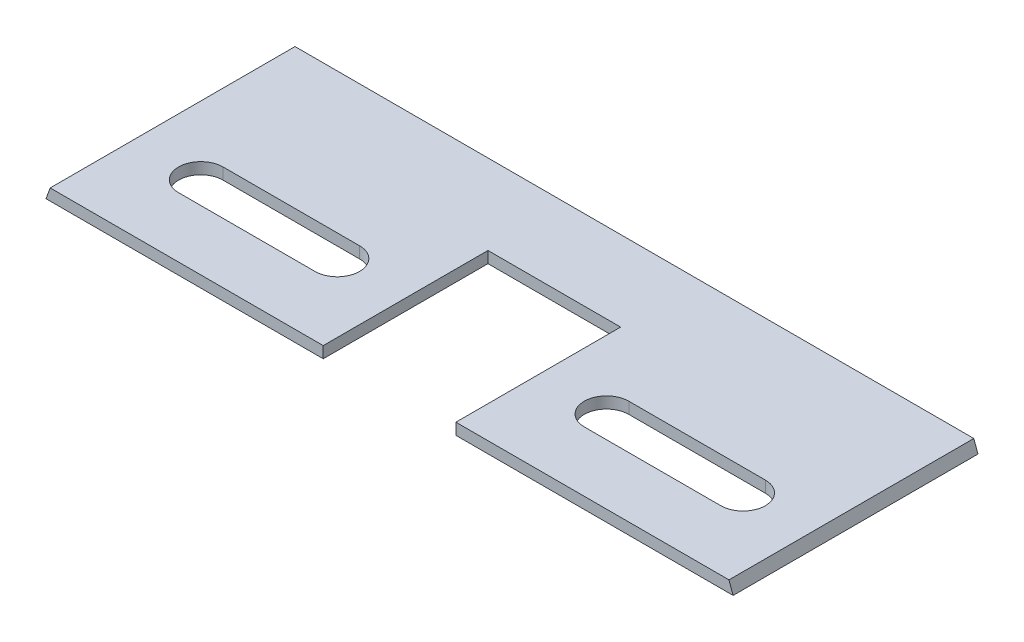
from build123d import *

# Parameters (mm, degrees)
BOSS_EXTRUDE1_DEPTH = 55
CUT_EXTRUDE4_DEPTH  = 3
CUT_EXTRUDE5_DEPTH  = 3


with BuildPart() as part:
    # Sketch3 → Boss-Extrude1 (new body)
    with BuildSketch(Plane.XY):
        Polygon((-76.265076845, 1.199033895), (-77.169023428, -1.284538931), (77.169023428, -1.284538931), (76.265076845, 1.199033895), (76.233955557, 1.284538931), (76.075119575, 1.284538931), (-76.233955557, 1.284538931), align=None)
    extrude(amount=-BOSS_EXTRUDE1_DEPTH)

    # Sketch4 → Cut-Extrude4 (cut)
    with BuildSketch(Plane(origin=(0, 1.284538931, 0), x_dir=(1, 0, 0), z_dir=(0, 1, 0))):
        Polygon((-14.9, 0), (-14.9, 37), (14.9, 37), (14.9, 0.115445968), (14.9, -2.514676192), (-14.9, -2.514676192), align=None)
    extrude(amount=-CUT_EXTRUDE4_DEPTH, mode=Mode.SUBTRACT)

    # Sketch5 → Cut-Extrude5 (cut)
    with BuildSketch(Plane(origin=(0, 1.284538931, 0), x_dir=(1, 0, 0), z_dir=(0, 1, 0))):
        with BuildLine():
            Line((-60.900466668, 23.5), (-30.233488889, 23.5))
            ThreePointArc((-30.233488889, 23.5), (-25.233488889, 18.5), (-30.233488889, 13.5))
            Line((-30.233488889, 13.5), (-60.900466668, 13.5))
            ThreePointArc((-60.900466668, 13.5), (-65.900466668, 18.5), (-60.900466668, 23.5))
        make_face()
        with BuildLine():
            Line((60.900466668, 13.5), (30.233488889, 13.5))
            ThreePointArc((30.233488889, 13.5), (25.233488889, 18.5), (30.233488889, 23.5))
            Line((30.233488889, 23.5), (60.900466668, 23.5))
            ThreePointArc((60.900466668, 23.5), (65.900466668, 18.5), (60.900466668, 13.5))
        make_face()
    extrude(amount=-CUT_EXTRUDE5_DEPTH, mode=Mode.SUBTRACT)


solid = part.part
